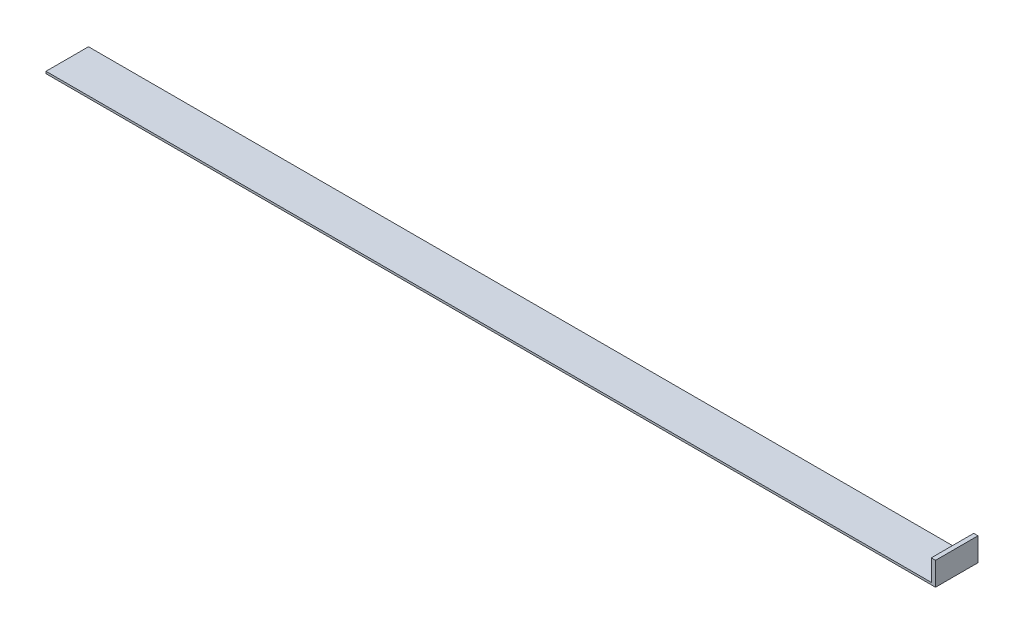
from build123d import *

# Parameters (mm, degrees)
SKETCH1_W           = 209.39
SKETCH1_H           = 10
BOSS_EXTRUDE1_DEPTH = 0.5
SKETCH2_W           = 1
SKETCH2_H           = 10
BOSS_EXTRUDE2_DEPTH = 5


with BuildPart() as part:
    # Sketch1 → Boss-Extrude1 (new body)
    with BuildSketch(Plane(origin=(0, 0, 0), x_dir=(1, 0, 0), z_dir=(0, 1, 0))):
        with Locations((104.695, 5)):
            Rectangle(SKETCH1_W, SKETCH1_H)
    extrude(amount=BOSS_EXTRUDE1_DEPTH)

    # Sketch2 → Boss-Extrude2 (add)
    with BuildSketch(Plane(origin=(0, 0.5, 0), x_dir=(1, 0, 0), z_dir=(0, 1, 0))):
        with Locations((208.89, 5)):
            Rectangle(SKETCH2_W, SKETCH2_H)
    extrude(amount=BOSS_EXTRUDE2_DEPTH)


solid = part.part
